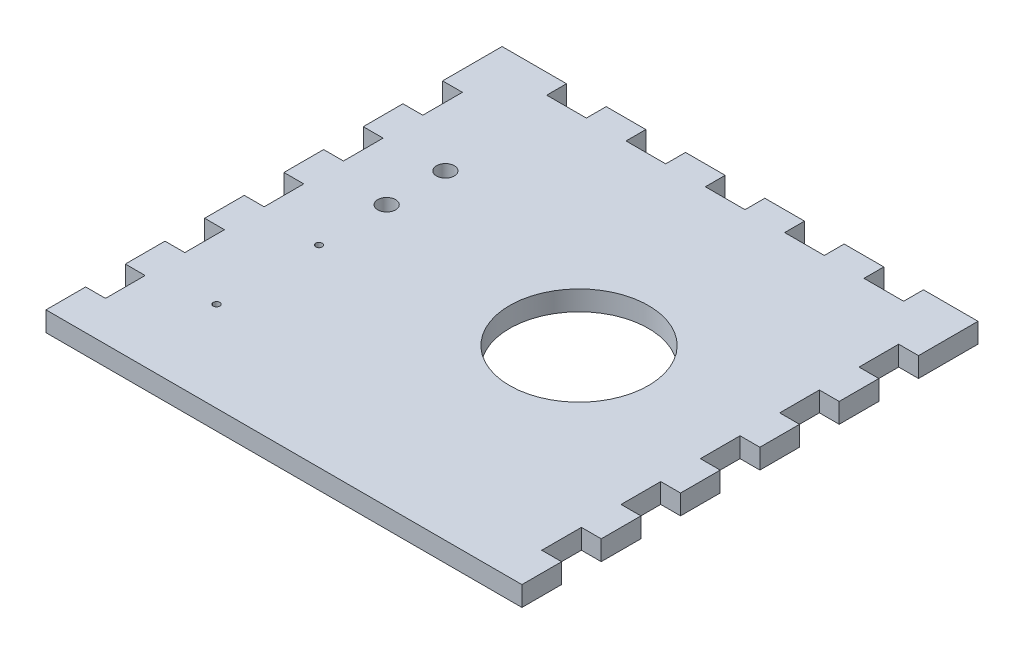
from build123d import *

# Parameters (mm, degrees)
SKETCH1_W               = 279.4
SKETCH1_H               = 279.4
BOSS_EXTRUDE1_DEPTH     = 12.7
SKETCH2_W               = 25.4
SKETCH2_H               = 12.7
BOSS_EXTRUDE2_DEPTH     = 12.7
LPATTERN1_COUNT         = 6
LPATTERN1_PITCH         = 50.8
MIRROR1_COPY_1_SKETCH_W = 25.4
MIRROR1_COPY_1_SKETCH_H = 12.7
MIRROR1_COPY_1_DEPTH    = 12.7
MIRROR1_COPY_2_SKETCH_W = 25.4
MIRROR1_COPY_2_SKETCH_H = 12.7
MIRROR1_COPY_2_DEPTH    = 12.7
MIRROR1_COPY_3_SKETCH_W = 25.4
MIRROR1_COPY_3_SKETCH_H = 12.7
MIRROR1_COPY_3_DEPTH    = 12.7
MIRROR1_COPY_4_SKETCH_W = 25.4
MIRROR1_COPY_4_SKETCH_H = 12.7
MIRROR1_COPY_4_DEPTH    = 12.7
MIRROR1_COPY_5_SKETCH_W = 25.4
MIRROR1_COPY_5_SKETCH_H = 12.7
MIRROR1_COPY_5_DEPTH    = 12.7
SKETCH3_W               = 25.4
SKETCH3_H               = 12.7
BOSS_EXTRUDE3_DEPTH     = 12.7
LPATTERN2_COUNT         = 6
LPATTERN2_PITCH         = 50.8
SKETCH5_W               = 17.00363529
SKETCH5_H               = 12.7
BOSS_EXTRUDE4_DEPTH     = 12.7
SKETCH6_R               = 44.45
CUT_EXTRUDE1_DEPTH      = 13.7
SKETCH7_R               = 5.715
CUT_EXTRUDE2_DEPTH      = 13.7
SKETCH8_R               = 2.1
CUT_EXTRUDE3_DEPTH      = 13.7


with BuildPart() as part:
    # Sketch1 → Boss-Extrude1 (new body)
    with BuildSketch(Plane(origin=(0, 0, 0), x_dir=(1, 0, 0), z_dir=(0, 1, 0))):
        Rectangle(SKETCH1_W, SKETCH1_H)
    extrude(amount=BOSS_EXTRUDE1_DEPTH)

    # Sketch2 → Boss-Extrude2 (add)
    with BuildSketch(Plane(origin=(139.7, 0, 0), x_dir=(0, 0, -1), z_dir=(1, 0, 0))):
        with Locations((-127, 6.35)):
            Rectangle(SKETCH2_W, SKETCH2_H)
    boss_extrude2 = extrude(amount=BOSS_EXTRUDE2_DEPTH)

    # LPattern1: Boss-Extrude2 ×6
    with Locations(*[(0, 0, -i * LPATTERN1_PITCH) for i in range(1, LPATTERN1_COUNT)]):
        add(boss_extrude2)

    # Mirror1: Boss-Extrude2 across plane
    add(boss_extrude2.mirror(Plane(origin=(0, 0, 0), x_dir=(0, 0, 1), z_dir=(1, 0, 0))))

    # Mirror1 copy 1 sketch → Mirror1 copy 1 (add)
    with BuildSketch(Plane(origin=(-139.7, 0, -50.8), x_dir=(0, 0, -1), z_dir=(-1, 0, 0))):
        with Locations((-127, -6.35)):
            Rectangle(MIRROR1_COPY_1_SKETCH_W, MIRROR1_COPY_1_SKETCH_H)
    extrude(amount=MIRROR1_COPY_1_DEPTH)

    # Mirror1 copy 2 sketch → Mirror1 copy 2 (add)
    with BuildSketch(Plane(origin=(-139.7, 0, -101.6), x_dir=(0, 0, -1), z_dir=(-1, 0, 0))):
        with Locations((-127, -6.35)):
            Rectangle(MIRROR1_COPY_2_SKETCH_W, MIRROR1_COPY_2_SKETCH_H)
    extrude(amount=MIRROR1_COPY_2_DEPTH)

    # Mirror1 copy 3 sketch → Mirror1 copy 3 (add)
    with BuildSketch(Plane(origin=(-139.7, 0, -152.4), x_dir=(0, 0, -1), z_dir=(-1, 0, 0))):
        with Locations((-127, -6.35)):
            Rectangle(MIRROR1_COPY_3_SKETCH_W, MIRROR1_COPY_3_SKETCH_H)
    extrude(amount=MIRROR1_COPY_3_DEPTH)

    # Mirror1 copy 4 sketch → Mirror1 copy 4 (add)
    with BuildSketch(Plane(origin=(-139.7, 0, -203.2), x_dir=(0, 0, -1), z_dir=(-1, 0, 0))):
        with Locations((-127, -6.35)):
            Rectangle(MIRROR1_COPY_4_SKETCH_W, MIRROR1_COPY_4_SKETCH_H)
    extrude(amount=MIRROR1_COPY_4_DEPTH)

    # Mirror1 copy 5 sketch → Mirror1 copy 5 (add)
    with BuildSketch(Plane(origin=(-139.7, 0, -254), x_dir=(0, 0, -1), z_dir=(-1, 0, 0))):
        with Locations((-127, -6.35)):
            Rectangle(MIRROR1_COPY_5_SKETCH_W, MIRROR1_COPY_5_SKETCH_H)
    extrude(amount=MIRROR1_COPY_5_DEPTH)

    # Sketch3 → Boss-Extrude3 (add)
    with BuildSketch(Plane(origin=(0, 0, -139.7), x_dir=(-1, 0, 0), z_dir=(0, 0, -1))):
        with Locations((-130.175, 6.35)):
            Rectangle(SKETCH3_W, SKETCH3_H)
    boss_extrude3 = extrude(amount=BOSS_EXTRUDE3_DEPTH)

    # LPattern2: Boss-Extrude3 ×6
    with Locations(*[(-i * LPATTERN2_PITCH, 0, 0) for i in range(1, LPATTERN2_COUNT)]):
        add(boss_extrude3)

    # Sketch5 → Boss-Extrude4 (add)
    with BuildSketch(Plane(origin=(0, 0, -139.7), x_dir=(-1, 0, 0), z_dir=(0, 0, -1))):
        with Locations((-143.898182355, 6.35)):
            Rectangle(SKETCH5_W, SKETCH5_H)
    boss_extrude4 = extrude(amount=BOSS_EXTRUDE4_DEPTH)

    # Mirror2: Boss-Extrude4 across plane
    add(boss_extrude4.mirror(Plane(origin=(0, 0, 0), x_dir=(0, 0, 1), z_dir=(1, 0, 0))))

    # Sketch6 → Cut-Extrude1 (cut, through all)
    with BuildSketch(Plane(origin=(0, 12.7, 0), x_dir=(1, 0, 0), z_dir=(0, 1, 0))):
        with Locations((38.1, 11.176)):
            Circle(SKETCH6_R)
    extrude(amount=-CUT_EXTRUDE1_DEPTH, mode=Mode.SUBTRACT)

    # Sketch7 → Cut-Extrude2 (cut, through all)
    with BuildSketch(Plane(origin=(0, 12.7, 0), x_dir=(1, 0, 0), z_dir=(0, 1, 0))):
        with Locations((-101.6, 65.278)):
            Circle(SKETCH7_R)
        with Locations((-101.6, 27.686)):
            Circle(SKETCH7_R)
    extrude(amount=-CUT_EXTRUDE2_DEPTH, mode=Mode.SUBTRACT)

    # Sketch8 → Cut-Extrude3 (cut, through all)
    with BuildSketch(Plane(origin=(0, 12.7, 0), x_dir=(1, 0, 0), z_dir=(0, 1, 0))):
        with Locations((-100.9, -81.986081859)):
            Circle(SKETCH8_R)
        with Locations((-100.9, -16.378881859)):
            Circle(SKETCH8_R)
    extrude(amount=-CUT_EXTRUDE3_DEPTH, mode=Mode.SUBTRACT)


solid = part.part
